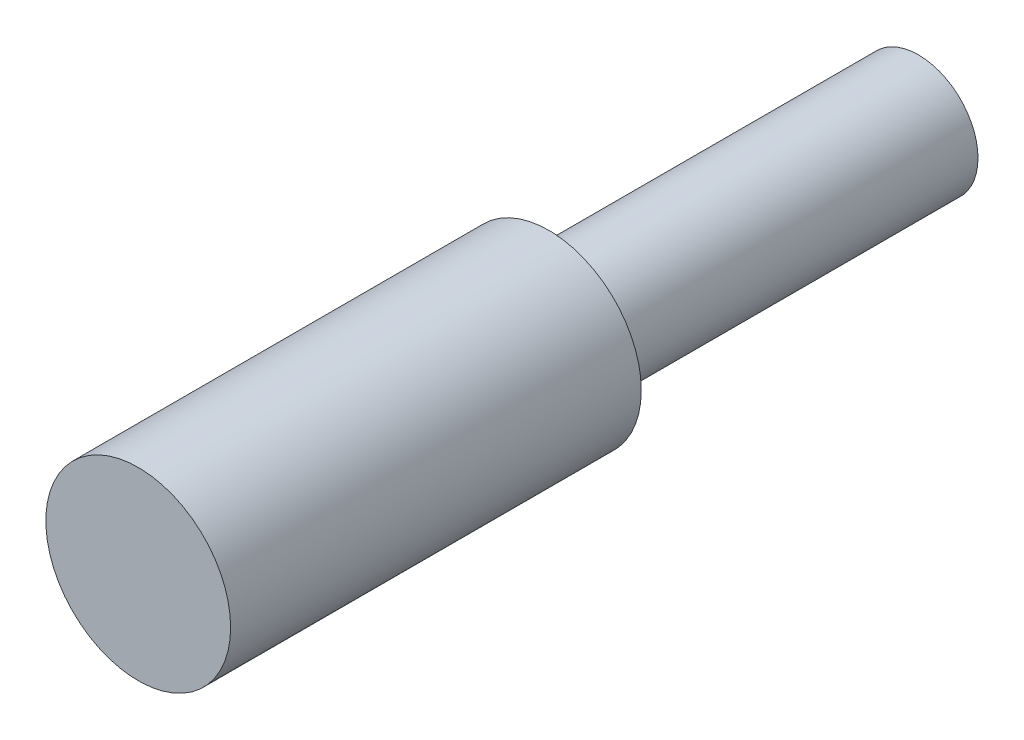
from build123d import *

# Parameters (mm, degrees)
SKETCH2_R           = 2.25
BOSS_EXTRUDE1_DEPTH = 10
SKETCH3_R           = 1.45
BOSS_EXTRUDE2_DEPTH = 9


with BuildPart() as part:
    # Sketch2 → Boss-Extrude1 (new body)
    with BuildSketch(Plane.XY):
        Circle(SKETCH2_R)
    extrude(amount=BOSS_EXTRUDE1_DEPTH)

    # Sketch3 → Boss-Extrude2 (add)
    with BuildSketch(Plane(origin=(0, 0, 0), x_dir=(-1, 0, 0), z_dir=(0, 0, -1))):
        Circle(SKETCH3_R)
    extrude(amount=BOSS_EXTRUDE2_DEPTH)


solid = part.part
